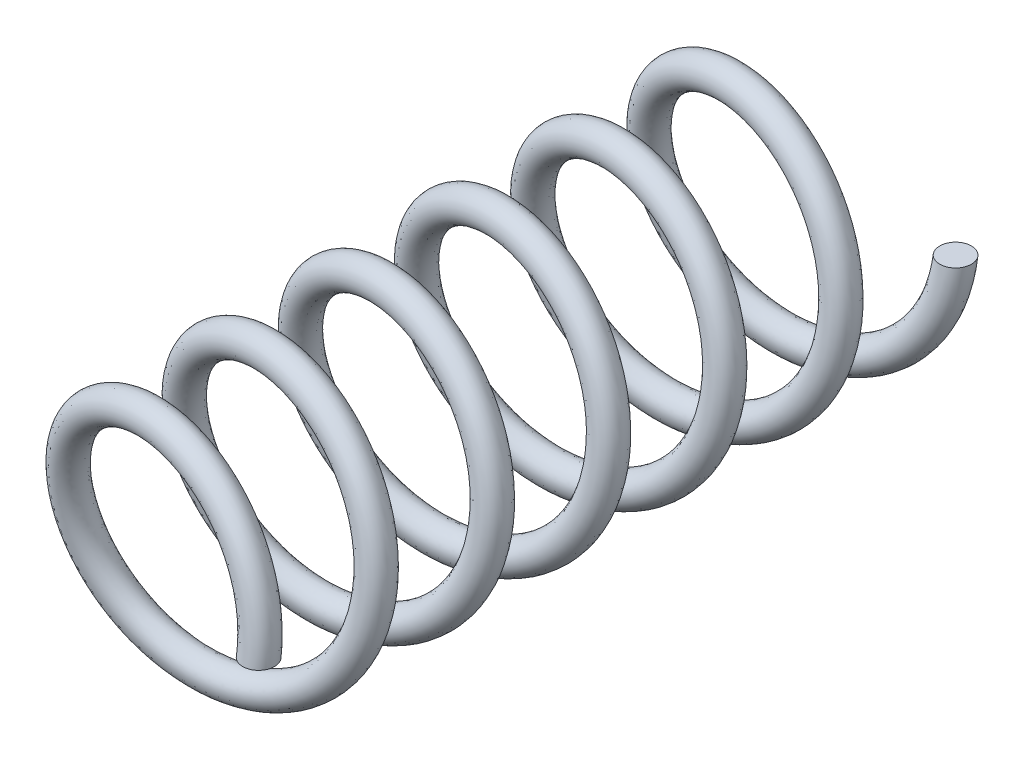
from build123d import *

# Parameters (mm, degrees)
SPRING_PITCH  = 23.283333333
SPRING_HEIGHT = 139.7
SPRING_RADIUS = 24.765
SKETCH2_R     = 3.175


with BuildPart() as part:
    # Spring: sweep along a helix
    with BuildLine() as spring_path:
        Helix(SPRING_PITCH, SPRING_HEIGHT, SPRING_RADIUS, center=(0, 0, 0), direction=(0, 0, 1), lefthand=True)
    # Sketch2 → Spring (sweep)
    with BuildSketch(Plane(origin=(0, 0, 0), x_dir=(1, 0, 0), z_dir=(0, 1, 0))):
        with Locations((24.765, -139.7)):
            Circle(SKETCH2_R)
    sweep(path=spring_path.line, is_frenet=True)


solid = part.part
